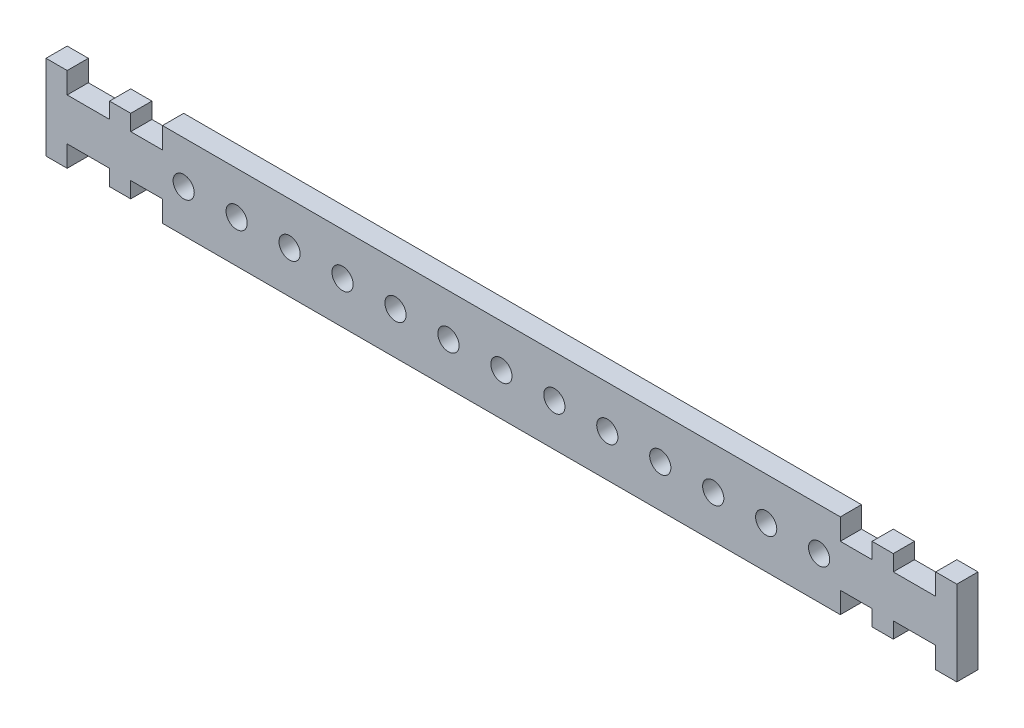
from build123d import *

# Parameters (mm, degrees)
SKETCH_1_R      = 1.000000004
EXTRUDE_1_DEPTH = 2


with BuildPart() as part:
    # 草图1 → 凸台-拉伸1 (new body)
    with BuildSketch(Plane.XY):
        Polygon((-31.999107626, 4), (32.000892374, 4), (32.000892374, 2), (35.000892374, 2), (35.000892374, 3.5), (37.000892374, 3.5), (37.000892374, 2), (41.000892374, 2), (41.000892374, 4), (43.000892374, 4), (43.000892374, -4), (41.000892374, -4), (41.000892374, -2), (37.000892374, -2), (37.000892374, -3.5), (35.000892374, -3.5), (35.000892374, -2), (32.000892374, -2), (32.000892374, -4), (-31.999107626, -4), (-31.999107626, -2), (-34.999107626, -2), (-34.999107626, -3.5), (-36.999107626, -3.5), (-36.999107626, -2), (-40.999107626, -2), (-40.999107626, -4), (-42.999107626, -4), (-42.999107626, 4), (-40.999107626, 4), (-40.999107626, 2), (-36.999107626, 2), (-36.999107626, 3.5), (-34.999107626, 3.5), (-34.999107626, 2), (-31.999107626, 2), align=None)
        with Locations((0.000892374, 0)):
            Circle(SKETCH_1_R, mode=Mode.SUBTRACT)
        with Locations((5.000892374, 0)):
            Circle(SKETCH_1_R, mode=Mode.SUBTRACT)
        with Locations((10.000892374, 0)):
            Circle(SKETCH_1_R, mode=Mode.SUBTRACT)
        with Locations((15.000892374, 0)):
            Circle(SKETCH_1_R, mode=Mode.SUBTRACT)
        with Locations((20.000892374, 0)):
            Circle(SKETCH_1_R, mode=Mode.SUBTRACT)
        with Locations((25.000892374, 0)):
            Circle(SKETCH_1_R, mode=Mode.SUBTRACT)
        with Locations((30.000892374, 0)):
            Circle(SKETCH_1_R, mode=Mode.SUBTRACT)
        with Locations((-4.999107626, 0)):
            Circle(SKETCH_1_R, mode=Mode.SUBTRACT)
        with Locations((-9.999107626, 0)):
            Circle(SKETCH_1_R, mode=Mode.SUBTRACT)
        with Locations((-14.999107626, 0)):
            Circle(SKETCH_1_R, mode=Mode.SUBTRACT)
        with Locations((-19.999107626, 0)):
            Circle(SKETCH_1_R, mode=Mode.SUBTRACT)
        with Locations((-24.999107626, 0)):
            Circle(SKETCH_1_R, mode=Mode.SUBTRACT)
        with Locations((-29.999107626, 0)):
            Circle(SKETCH_1_R, mode=Mode.SUBTRACT)
    extrude(amount=EXTRUDE_1_DEPTH)


solid = part.part
